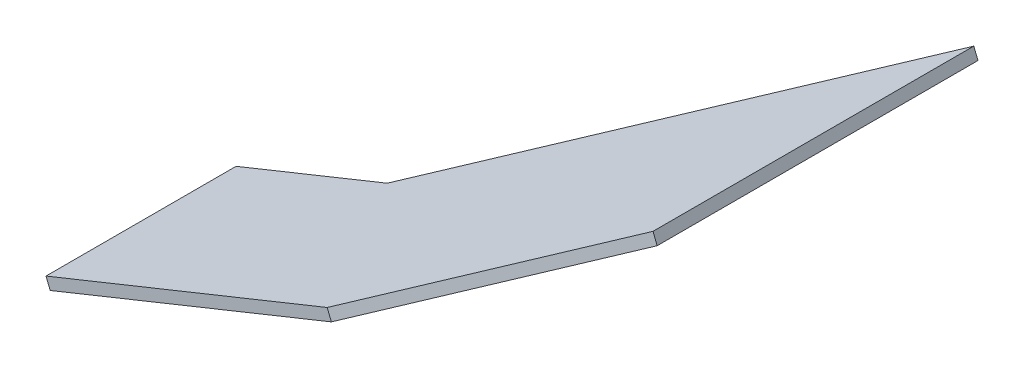
from build123d import *

# Parameters (mm, degrees)
BOSS_EXTRUDE1_DEPTH = 3


with BuildPart() as part:
    # Sketch2 → Boss-Extrude1 (new body)
    with BuildSketch(Plane(origin=(-347.997301686, 863.116155105, 7.6e-08), x_dir=(0.927453922, 0.373937459, 0), z_dir=(0.373937459, -0.927453922, 0))):
        Polygon((6688.476475049, -11775.449012078), (6688.476475049, -11826.310577196), (6732.085815802, -11826.310577196), (6816.476475047, -11905.006140071), (6816.476475047, -11819.156826678), (6769.605582286, -11775.449012078), align=None)
    extrude(amount=BOSS_EXTRUDE1_DEPTH)


solid = part.part
